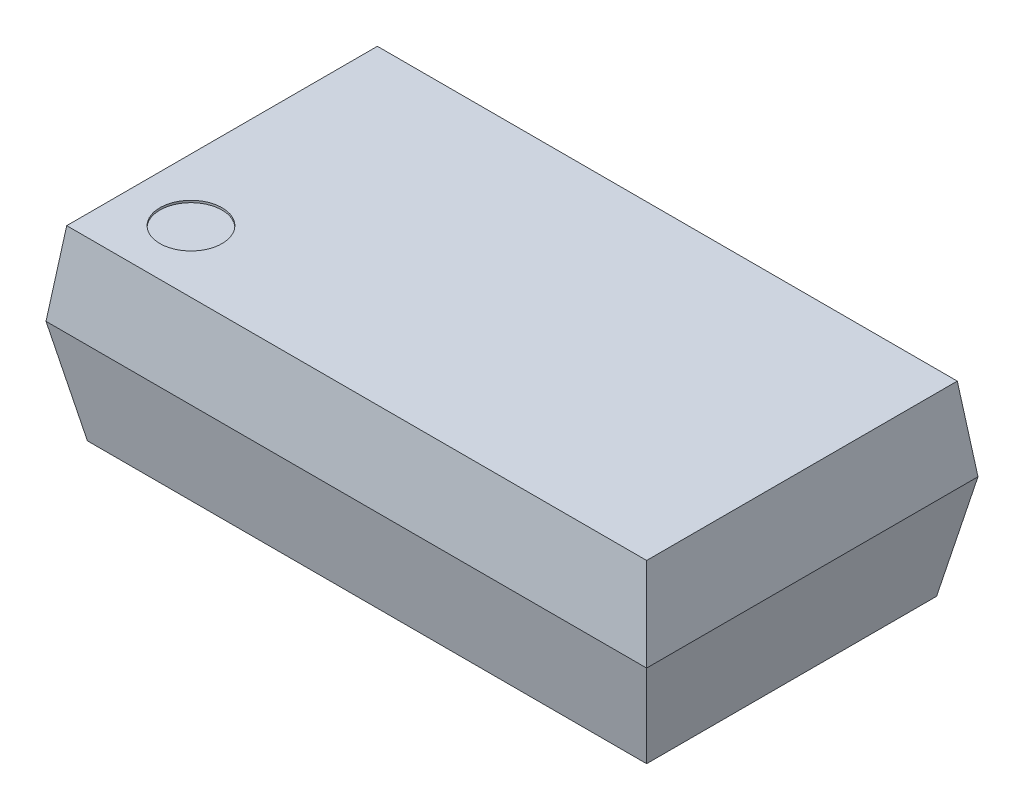
from build123d import *

# Parameters (mm, degrees)
SKETCH1_W           = 2.9
SKETCH1_H           = 1.6
BOSS_EXTRUDE1_DEPTH = 0.9
CUT_EXTRUDE1_DEPTH  = 2.45
CUT_EXTRUDE2_DEPTH  = 2.45
CUT_EXTRUDE3_DEPTH  = 1.8
CUT_EXTRUDE4_DEPTH  = 1.8
SKETCH6_R           = 0.15
CUT_EXTRUDE5_DEPTH  = 0.01


with BuildPart() as part:
    # Sketch1 → Boss-Extrude1 (new body)
    with BuildSketch(Plane(origin=(0, 0, 0), x_dir=(1, 0, 0), z_dir=(0, 1, 0))):
        Rectangle(SKETCH1_W, SKETCH1_H)
    extrude(amount=BOSS_EXTRUDE1_DEPTH)

    # Sketch2 → Cut-Extrude1 (cut, symmetric)
    with BuildSketch(Plane(origin=(0, 0, 0), x_dir=(0, 0, -1), z_dir=(1, 0, 0))):
        Polygon((-0.8, 0.5), (-0.7, 0), (-0.8, 0), align=None)
    cut_extrude1 = extrude(amount=CUT_EXTRUDE1_DEPTH, both=True, mode=Mode.SUBTRACT)

    # Mirror1: Cut-Extrude1 across plane
    add(cut_extrude1.mirror(Plane.XY), mode=Mode.SUBTRACT)

    # Sketch3 → Cut-Extrude2 (cut, symmetric)
    with BuildSketch(Plane(origin=(0, 0, 0), x_dir=(0, 0, -1), z_dir=(1, 0, 0))):
        Polygon((-0.8, 0.5), (-0.75, 0.9), (-0.8, 0.9), align=None)
    cut_extrude2 = extrude(amount=CUT_EXTRUDE2_DEPTH, both=True, mode=Mode.SUBTRACT)

    # Mirror2: Cut-Extrude2 across plane
    add(cut_extrude2.mirror(Plane.XY), mode=Mode.SUBTRACT)

    # Sketch4 → Cut-Extrude3 (cut, symmetric)
    with BuildSketch(Plane.XY):
        Polygon((-1.45, 0.5), (-1.35, 0), (-1.45, 0), align=None)
    cut_extrude3 = extrude(amount=CUT_EXTRUDE3_DEPTH, both=True, mode=Mode.SUBTRACT)

    # Mirror3: Cut-Extrude3 across plane
    add(cut_extrude3.mirror(Plane(origin=(0, 0, 0), x_dir=(0, 0, 1), z_dir=(1, 0, 0))), mode=Mode.SUBTRACT)

    # Sketch5 → Cut-Extrude4 (cut, symmetric)
    with BuildSketch(Plane.XY):
        Polygon((-1.45, 0.5), (-1.4, 0.9), (-1.45, 0.9), align=None)
    cut_extrude4 = extrude(amount=CUT_EXTRUDE4_DEPTH, both=True, mode=Mode.SUBTRACT)

    # Mirror4: Cut-Extrude4 across plane
    add(cut_extrude4.mirror(Plane(origin=(0, 0, 0), x_dir=(0, 0, 1), z_dir=(1, 0, 0))), mode=Mode.SUBTRACT)

    # Sketch6 → Cut-Extrude5 (cut)
    with BuildSketch(Plane(origin=(0, 0.9, 0), x_dir=(1, 0, 0), z_dir=(0, 1, 0))):
        with Locations((-1.1, -0.45)):
            Circle(SKETCH6_R)
    extrude(amount=-CUT_EXTRUDE5_DEPTH, mode=Mode.SUBTRACT)


solid = part.part
